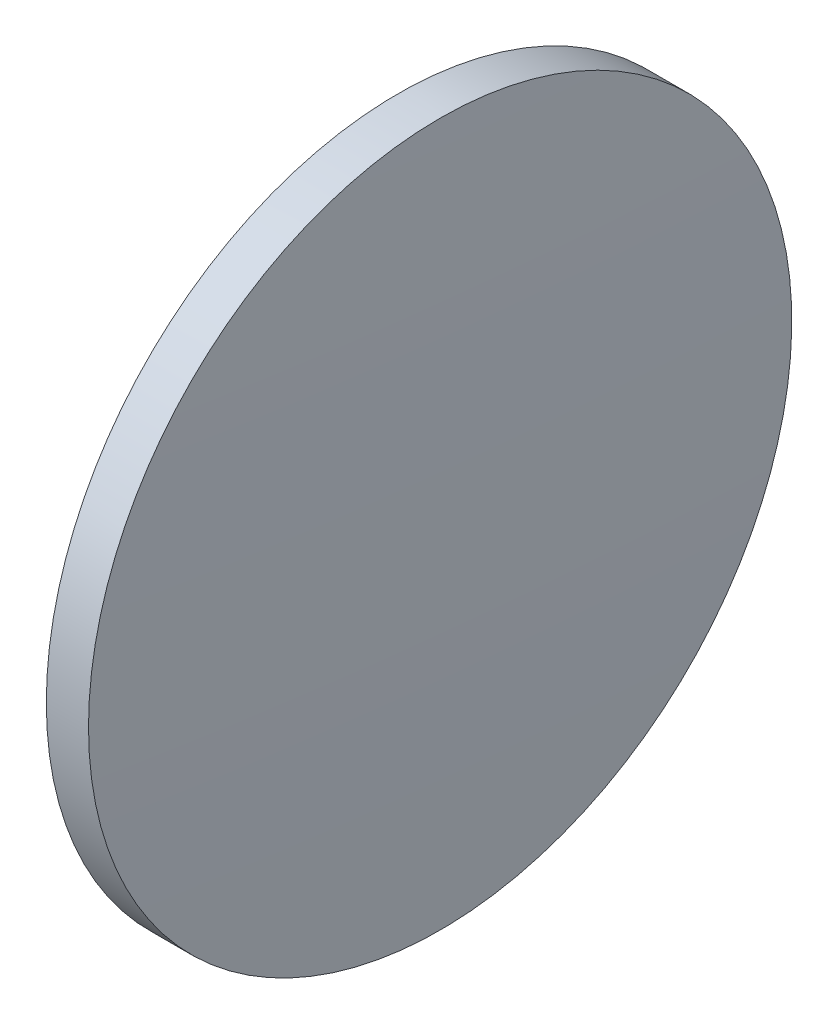
from build123d import *


with BuildPart() as part:
    # 草图1 → 旋转1 (revolve)
    with BuildSketch(Plane.XY):
        with BuildLine():
            Line((56.560024263, 32.629645364), (56.560024263, 45.129645364))
            Line((56.560024263, 45.129645364), (58.060024263, 45.129645364))
            ThreePointArc((58.060024263, 45.129645364), (58.210021063, 38.880445313), (58.260024263, 32.629645364))
            Line((58.260024263, 32.629645364), (56.560024263, 32.629645364))
        make_face()
    revolve(axis=Axis((54.530916684, 32.629645364, 0), (1, 0, 0)))


solid = part.part
